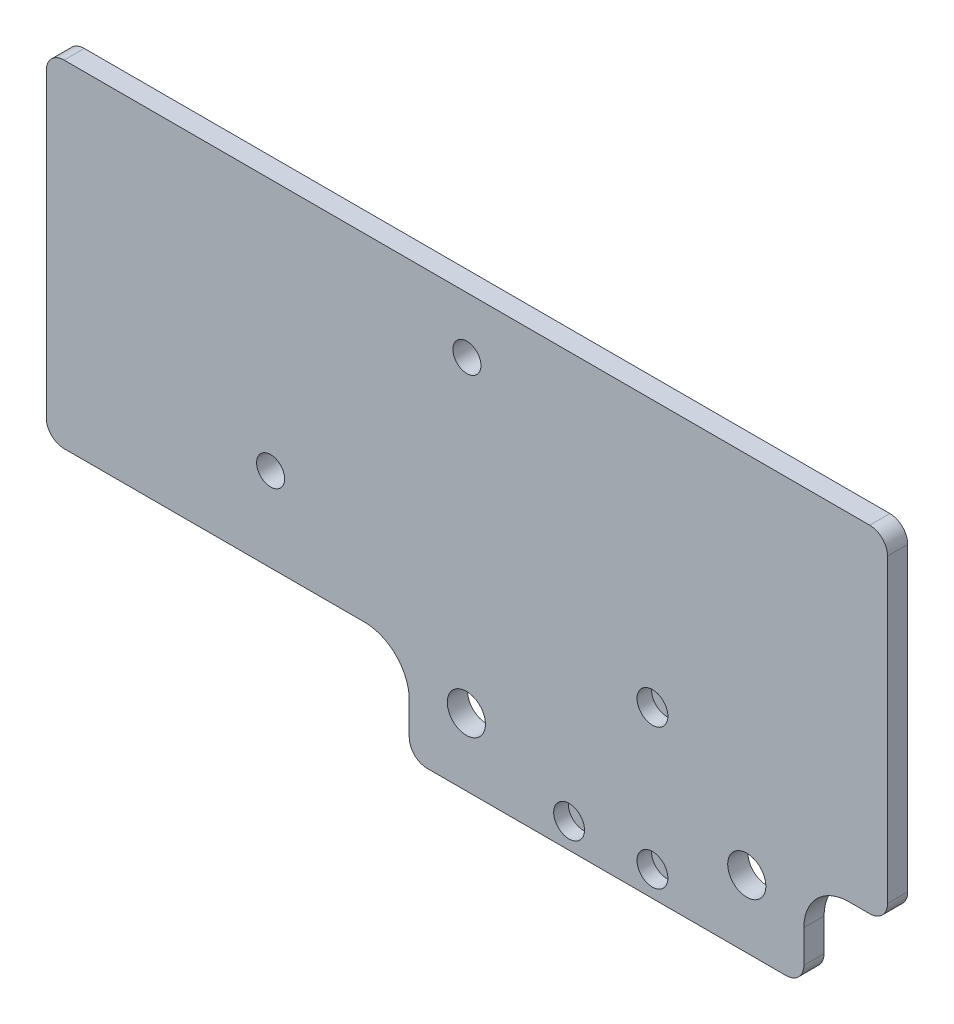
from build123d import *

# Parameters (mm, degrees)
SKETCH1_R           = 2.5
SKETCH1_R_2         = 3.4
SKETCH1_R_3         = 2.75
BOSS_EXTRUDE1_DEPTH = 3.6
SKETCH3_W           = 22.86
SKETCH3_H           = 34.5
BOSS_EXTRUDE3_DEPTH = 1


with BuildPart() as part:
    # Sketch1 → Boss-Extrude1 (new body)
    with BuildSketch(Plane.XY):
        with BuildLine():
            Line((71.82, 0), (-71.82, 0))
            ThreePointArc((-71.82, 0), (-74.068599564, -0.931400436), (-75, -3.18))
            Line((-75, -3.18), (-75, -56.82))
            ThreePointArc((-75, -56.82), (-74.068599564, -59.068599564), (-71.82, -60))
            Line((-71.82, -60), (-18.28, -60))
            ThreePointArc((-18.28, -60), (-12.623145751, -62.343145751), (-10.28, -68))
            Line((-10.28, -68), (-10.28, -73.82))
            ThreePointArc((-10.28, -73.82), (-9.348599564, -76.068599564), (-7.1, -77))
            Line((-7.1, -77), (56.9, -77))
            ThreePointArc((56.9, -77), (59.148599564, -76.068599564), (60.08, -73.82))
            Line((60.08, -73.82), (60.08, -68))
            ThreePointArc((60.08, -68), (62.423145751, -62.343145751), (68.08, -60))
            Line((68.08, -60), (71.82, -60))
            ThreePointArc((71.82, -60), (74.068599564, -59.068599564), (75, -56.82))
            Line((75, -56.82), (75, -3.18))
            ThreePointArc((75, -3.18), (74.068599564, -0.931400436), (71.82, 0))
        make_face()
        with Locations((-35, -45)):
            Circle(SKETCH1_R, mode=Mode.SUBTRACT)
        with Locations((0, -10)):
            Circle(SKETCH1_R, mode=Mode.SUBTRACT)
        with Locations((-0.1, -65)):
            Circle(SKETCH1_R_2, mode=Mode.SUBTRACT)
        with Locations((49.9, -65)):
            Circle(SKETCH1_R_2, mode=Mode.SUBTRACT)
        with Locations((33.08, -72.5)):
            Circle(SKETCH1_R_3, mode=Mode.SUBTRACT)
        with Locations((18.22, -72.5)):
            Circle(SKETCH1_R_3, mode=Mode.SUBTRACT)
        with Locations((33.08, -47.5)):
            Circle(SKETCH1_R_3, mode=Mode.SUBTRACT)
    extrude(amount=BOSS_EXTRUDE1_DEPTH)

    # Sketch3 → Boss-Extrude3 (add)
    with BuildSketch(Plane(origin=(0, 0, 0), x_dir=(-1, 0, 0), z_dir=(0, 0, -1))):
        with Locations((-25.65, -59.75)):
            Rectangle(SKETCH3_W, SKETCH3_H)
    extrude(amount=-BOSS_EXTRUDE3_DEPTH)


solid = part.part
